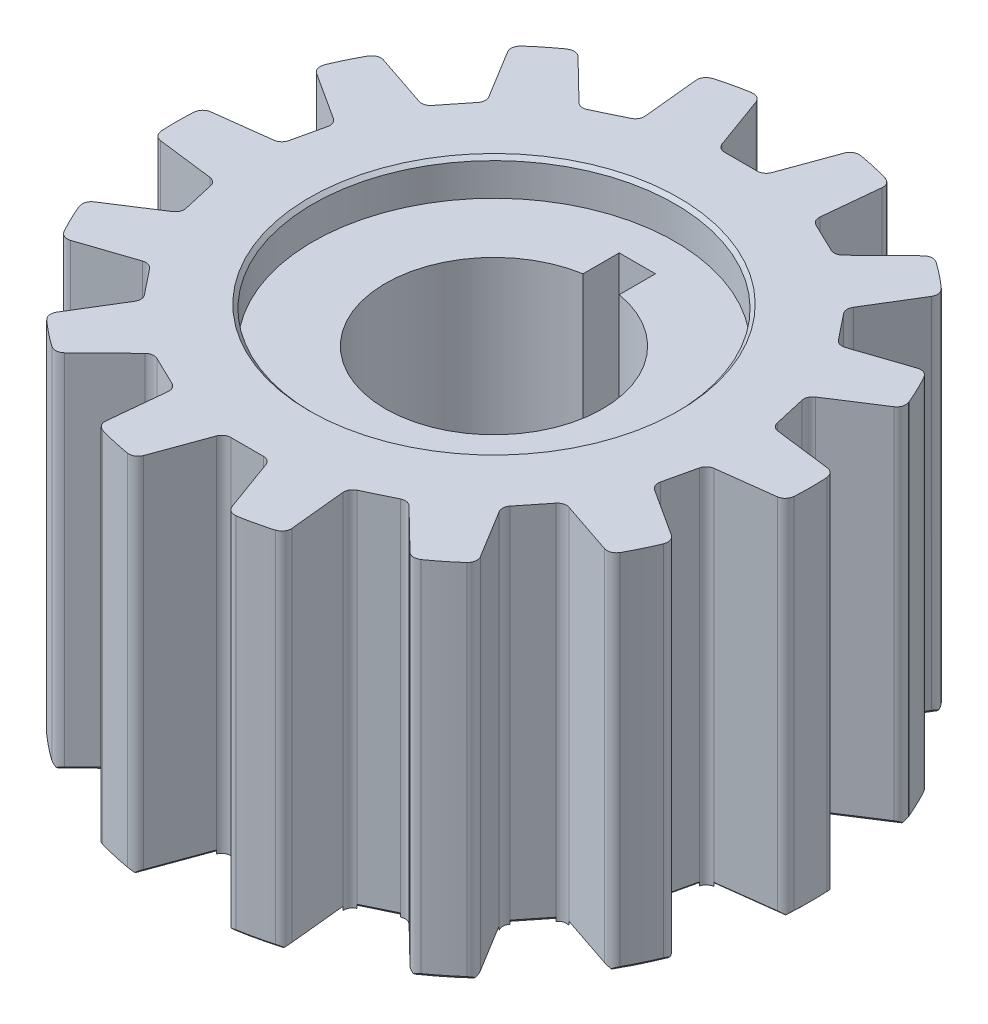
from build123d import *

# Parameters (mm, degrees)
CROQUIS1_R              = 17.5
CROQUIS1_R_2            = 6
SALIENTE_EXTRUIR1_DEPTH = 20
CORTAR_EXTRUIR2_DEPTH   = 20
CORTAR_EXTRUIR3_DEPTH   = 20
CROQUIS4_R              = 10
CORTAR_EXTRUIR4_DEPTH   = 2
CROQUIS5_R              = 10
CORTAR_EXTRUIR5_DEPTH   = 2
CHAFL_N2_SIZE           = 0.2
CHAFL_N3_SIZE           = 0.2
SALIENTE_EXTRUIR3_DEPTH = 20
CORTAR_EXTRUIR9_DEPTH   = 20


with BuildPart() as part:
    # Croquis1 → Saliente-Extruir1 (new body)
    with BuildSketch(Plane(origin=(0, 0, 0), x_dir=(1, 0, 0), z_dir=(0, 1, 0))):
        Circle(CROQUIS1_R)
        Circle(CROQUIS1_R_2, mode=Mode.SUBTRACT)
    extrude(amount=SALIENTE_EXTRUIR1_DEPTH)

    # Croquis2 → Cortar-Extruir2 (cut)
    with BuildSketch(Plane(origin=(0, 20, 0), x_dir=(1, 0, 0), z_dir=(0, 1, 0))):
        with BuildLine():
            Line((5.915999659, 12.284699873), (7.042210744, 11.7423452))
            Line((7.042210744, 11.7423452), (9.84016384, 14.471391626))
            ThreePointArc((9.84016384, 14.471391626), (7.592965435, 15.766955188), (5.178947766, 16.71611498))
            Line((5.178947766, 16.71611498), (4.789788574, 12.827054547))
            Line((4.789788574, 12.827054547), (5.915999659, 12.284699873))
        make_face()
        with BuildLine():
            Line((0, 13.63498819), (-1.25, 13.63498819))
            Line((-1.25, 13.63498819), (-2.586779766, 17.307760411))
            ThreePointArc((-2.586779766, 17.307760411), (0, 17.5), (2.586779766, 17.307760411))
            Line((2.586779766, 17.307760411), (1.25, 13.63498819))
            Line((1.25, 13.63498819), (0, 13.63498819))
        make_face()
        with BuildLine():
            Line((10.66026303, 8.501276085), (11.439625282, 7.523986732))
            Line((11.439625282, 7.523986732), (15.144582784, 8.76878625))
            ThreePointArc((15.144582784, 8.76878625), (13.682050943, 10.911071533), (11.918921177, 12.813637968))
            Line((11.918921177, 12.813637968), (9.880900778, 9.478565438))
            Line((9.880900778, 9.478565438), (10.66026303, 8.501276085))
        make_face()
        with BuildLine():
            Line((13.293130569, 3.034070307), (13.571281736, 1.815410416))
            Line((13.571281736, 1.815410416), (17.449431371, 1.329415215))
            ThreePointArc((17.449431371, 1.329415215), (17.061238463, 3.894116344), (16.298206073, 6.373262808))
            Line((16.298206073, 6.373262808), (13.014979401, 4.252730197))
            Line((13.014979401, 4.252730197), (13.293130569, 3.034070307))
        make_face()
        with BuildLine():
            Line((13.293130569, -3.034070307), (13.014979401, -4.252730197))
            Line((13.014979401, -4.252730197), (16.298206073, -6.373262808))
            ThreePointArc((16.298206073, -6.373262808), (17.061238463, -3.894116344), (17.449431371, -1.329415215))
            Line((17.449431371, -1.329415215), (13.571281736, -1.815410416))
            Line((13.571281736, -1.815410416), (13.293130569, -3.034070307))
        make_face()
        with BuildLine():
            Line((10.66026303, -8.501276085), (9.880900778, -9.478565438))
            Line((9.880900778, -9.478565438), (11.918921177, -12.813637968))
            ThreePointArc((11.918921177, -12.813637968), (13.682050943, -10.911071533), (15.144582784, -8.76878625))
            Line((15.144582784, -8.76878625), (11.439625282, -7.523986732))
            Line((11.439625282, -7.523986732), (10.66026303, -8.501276085))
        make_face()
        with BuildLine():
            Line((5.915999659, -12.284699873), (4.789788574, -12.827054547))
            Line((4.789788574, -12.827054547), (5.178947766, -16.71611498))
            ThreePointArc((5.178947766, -16.71611498), (7.592965435, -15.766955188), (9.84016384, -14.471391626))
            Line((9.84016384, -14.471391626), (7.042210744, -11.7423452))
            Line((7.042210744, -11.7423452), (5.915999659, -12.284699873))
        make_face()
        with BuildLine():
            Line((0, -13.63498819), (-1.25, -13.63498819))
            Line((-1.25, -13.63498819), (-2.586779766, -17.307760411))
            ThreePointArc((-2.586779766, -17.307760411), (0, -17.5), (2.586779766, -17.307760411))
            Line((2.586779766, -17.307760411), (1.25, -13.63498819))
            Line((1.25, -13.63498819), (0, -13.63498819))
        make_face()
        with BuildLine():
            Line((-5.915999659, -12.284699873), (-7.042210744, -11.7423452))
            Line((-7.042210744, -11.7423452), (-9.84016384, -14.471391626))
            ThreePointArc((-9.84016384, -14.471391626), (-7.592965435, -15.766955188), (-5.178947766, -16.71611498))
            Line((-5.178947766, -16.71611498), (-4.789788574, -12.827054547))
            Line((-4.789788574, -12.827054547), (-5.915999659, -12.284699873))
        make_face()
        with BuildLine():
            Line((-10.66026303, -8.501276085), (-11.439625282, -7.523986732))
            Line((-11.439625282, -7.523986732), (-15.144582784, -8.76878625))
            ThreePointArc((-15.144582784, -8.76878625), (-13.682050943, -10.911071533), (-11.918921177, -12.813637968))
            Line((-11.918921177, -12.813637968), (-9.880900778, -9.478565438))
            Line((-9.880900778, -9.478565438), (-10.66026303, -8.501276085))
        make_face()
        with BuildLine():
            Line((-13.293130569, -3.034070307), (-13.571281736, -1.815410416))
            Line((-13.571281736, -1.815410416), (-17.449431371, -1.329415215))
            ThreePointArc((-17.449431371, -1.329415215), (-17.061238463, -3.894116344), (-16.298206073, -6.373262808))
            Line((-16.298206073, -6.373262808), (-13.014979401, -4.252730197))
            Line((-13.014979401, -4.252730197), (-13.293130569, -3.034070307))
        make_face()
        with BuildLine():
            Line((-13.293130569, 3.034070307), (-13.014979401, 4.252730197))
            Line((-13.014979401, 4.252730197), (-16.298206073, 6.373262808))
            ThreePointArc((-16.298206073, 6.373262808), (-17.061238463, 3.894116344), (-17.449431371, 1.329415215))
            Line((-17.449431371, 1.329415215), (-13.571281736, 1.815410416))
            Line((-13.571281736, 1.815410416), (-13.293130569, 3.034070307))
        make_face()
        with BuildLine():
            Line((-10.66026303, 8.501276085), (-9.880900778, 9.478565438))
            Line((-9.880900778, 9.478565438), (-11.918921177, 12.813637968))
            ThreePointArc((-11.918921177, 12.813637968), (-13.682050943, 10.911071533), (-15.144582784, 8.76878625))
            Line((-15.144582784, 8.76878625), (-11.439625282, 7.523986732))
            Line((-11.439625282, 7.523986732), (-10.66026303, 8.501276085))
        make_face()
        with BuildLine():
            Line((-5.915999659, 12.284699873), (-4.789788574, 12.827054547))
            Line((-4.789788574, 12.827054547), (-5.178947766, 16.71611498))
            ThreePointArc((-5.178947766, 16.71611498), (-7.592965435, 15.766955188), (-9.84016384, 14.471391626))
            Line((-9.84016384, 14.471391626), (-7.042210744, 11.7423452))
            Line((-7.042210744, 11.7423452), (-5.915999659, 12.284699873))
        make_face()
    extrude(amount=-CORTAR_EXTRUIR2_DEPTH, mode=Mode.SUBTRACT)

    # Croquis3 → Cortar-Extruir3 (cut)
    with BuildSketch(Plane(origin=(0, 20, 0), x_dir=(1, 0, 0), z_dir=(0, 1, 0))):
        with BuildLine():
            Line((-1, 5.916079783), (-1, 7.916079783))
            Line((-1, 7.916079783), (1, 7.916079783))
            Line((1, 7.916079783), (1, 5.916079783))
            ThreePointArc((1, 5.916079783), (0, 6), (-1, 5.916079783))
        make_face()
    extrude(amount=-CORTAR_EXTRUIR3_DEPTH, mode=Mode.SUBTRACT)

    # Croquis4 → Cortar-Extruir4 (cut)
    with BuildSketch(Plane(origin=(0, 20, 0), x_dir=(1, 0, 0), z_dir=(0, 1, 0))):
        Circle(CROQUIS4_R)
    extrude(amount=-CORTAR_EXTRUIR4_DEPTH, mode=Mode.SUBTRACT)

    # Croquis5 → Cortar-Extruir5 (cut)
    with BuildSketch(Plane.XZ):
        Circle(CROQUIS5_R)
    extrude(amount=-CORTAR_EXTRUIR5_DEPTH, mode=Mode.SUBTRACT)

    # Chaflán2
    chafl_n2_edges = [part.edges().sort_by_distance(p)[0] for p in [
        (10.899910977, 0, 11.146101703),
        (10.66026303, 0, 8.501276085),
        (13.292104033, 0, 8.146386491),
        (4.98436817, 0, 14.771584764),
        (5.915999659, 0, 12.284699873),
        (8.441187292, 0, 13.106868413),
        (-1.918389883, 0, 15.471374301),
        (0, 0, 13.63498819),
        (1.918389883, 0, 15.471374301),
        (-8.441187292, 0, 13.106868413),
        (-5.915999659, 0, 12.284699873),
        (-4.98436817, 0, 14.771584764),
        (-13.292104033, 0, 8.146386491),
        (-10.66026303, 0, 8.501276085),
        (-10.899910977, 0, 11.146101703),
        (-15.510356554, 0, 1.572412816),
        (-13.293130569, 0, 3.034070307),
        (-14.656592737, 0, 5.312996502),
        (-14.656592737, 0, -5.312996502),
        (-13.293130569, 0, -3.034070307),
        (-15.510356554, 0, -1.572412816),
        (-10.899910977, 0, -11.146101703),
        (-10.66026303, 0, -8.501276085),
        (-13.292104033, 0, -8.146386491),
        (-4.98436817, 0, -14.771584764),
        (-5.915999659, 0, -12.284699873),
        (-8.441187292, 0, -13.106868413),
        (1.918389883, 0, -15.471374301),
        (0, 0, -13.63498819),
        (-1.918389883, 0, -15.471374301),
        (10.911071533, 0, 13.682050943),
        (15.766955188, 0, 7.592965435),
        (17.5, 0, 0),
        (3.894116344, 0, 17.061238463),
        (15.766955188, 0, -7.592965435),
        (10.911071533, 0, -13.682050943),
        (3.894116344, 0, -17.061238463),
        (-3.894116344, 0, -17.061238463),
        (-10.911071533, 0, -13.682050943),
        (-15.766955188, 0, -7.592965435),
        (-17.5, 0, 0),
        (-15.766955188, 0, 7.592965435),
        (-10.911071533, 0, 13.682050943),
        (-3.894116344, 0, 17.061238463),
        (-10, 0, 0),
        (8.441187292, 0, -13.106868413),
        (5.915999659, 0, -12.284699873),
        (4.98436817, 0, -14.771584764),
        (13.292104033, 0, -8.146386491),
        (10.66026303, 0, -8.501276085),
        (10.899910977, 0, -11.146101703),
        (15.510356554, 0, -1.572412816),
        (13.293130569, 0, -3.034070307),
        (14.656592737, 0, -5.312996502),
        (14.656592737, 0, 5.312996502),
        (13.293130569, 0, 3.034070307),
        (15.510356554, 0, 1.572412816),
    ]]
    chamfer(chafl_n2_edges, length=CHAFL_N2_SIZE)

    # Chaflán3
    chafl_n3_edges = [part.edges().sort_by_distance(p)[0] for p in [
        (-10, 20, 0),
    ]]
    chamfer(chafl_n3_edges, length=CHAFL_N3_SIZE)

    # Croquis6 → Saliente-Extruir3 (add)
    with BuildSketch(Plane(origin=(0, 20, 0), x_dir=(1, 0, 0), z_dir=(0, 1, 0))):
        with BuildLine():
            Line((-11.771498219, 7.635490109), (-11.439625282, 7.523986732))
            Line((-11.439625282, 7.523986732), (-11.221339153, 7.797708881))
            ThreePointArc((-11.221339153, 7.797708881), (-11.470844995, 7.629867251), (-11.771498219, 7.635490109))
        make_face()
        with BuildLine():
            Line((-4.789788574, 12.827054547), (-4.824647652, 13.175418572))
            ThreePointArc((-4.824647652, 13.175418572), (-4.886067408, 12.881052148), (-5.10522117, 12.675150215))
            Line((-5.10522117, 12.675150215), (-4.789788574, 12.827054547))
        make_face()
        with BuildLine():
            Line((-10.099186907, 9.204843289), (-9.880900778, 9.478565438))
            Line((-9.880900778, 9.478565438), (-10.063457208, 9.777305792))
            ThreePointArc((-10.063457208, 9.777305792), (-9.991073691, 9.485441775), (-10.099186907, 9.204843289))
        make_face()
        with BuildLine():
            Line((-7.042210744, 11.7423452), (-6.726778147, 11.894249532))
            ThreePointArc((-6.726778147, 11.894249532), (-7.024398897, 11.851285977), (-7.292838426, 11.986800541))
            Line((-7.292838426, 11.986800541), (-7.042210744, 11.7423452))
        make_face()
        with BuildLine():
            Line((1.25, 13.63498819), (1.369742541, 13.963978118))
            ThreePointArc((1.369742541, 13.963978118), (1.186684449, 13.725412168), (0.899896231, 13.63498819))
            Line((0.899896231, 13.63498819), (1.25, 13.63498819))
        make_face()
        with BuildLine():
            Line((-1.25, 13.63498819), (-0.899896231, 13.63498819))
            ThreePointArc((-0.899896231, 13.63498819), (-1.186684449, 13.725412168), (-1.369742541, 13.963978118))
            Line((-1.369742541, 13.963978118), (-1.25, 13.63498819))
        make_face()
        with BuildLine():
            Line((7.042210744, 11.7423452), (7.292838426, 11.986800541))
            ThreePointArc((7.292838426, 11.986800541), (7.024398897, 11.851285977), (6.726778147, 11.894249532))
            Line((6.726778147, 11.894249532), (7.042210744, 11.7423452))
        make_face()
        with BuildLine():
            Line((4.789788574, 12.827054547), (5.10522117, 12.675150215))
            ThreePointArc((5.10522117, 12.675150215), (4.886067408, 12.881052148), (4.824647652, 13.175418572))
            Line((4.824647652, 13.175418572), (4.789788574, 12.827054547))
        make_face()
        with BuildLine():
            Line((11.439625282, 7.523986732), (11.771498219, 7.635490109))
            ThreePointArc((11.771498219, 7.635490109), (11.470844995, 7.629867251), (11.221339153, 7.797708881))
            Line((11.221339153, 7.797708881), (11.439625282, 7.523986732))
        make_face()
        with BuildLine():
            Line((9.880900778, 9.478565438), (10.099186907, 9.204843289))
            ThreePointArc((10.099186907, 9.204843289), (9.991073691, 9.485441775), (10.063457208, 9.777305792))
            Line((10.063457208, 9.777305792), (9.880900778, 9.478565438))
        make_face()
        with BuildLine():
            Line((13.571281736, 1.815410416), (13.918668422, 1.771877217))
            ThreePointArc((13.918668422, 1.771877217), (13.645349561, 1.897259742), (13.493376319, 2.156736353))
            Line((13.493376319, 2.156736353), (13.571281736, 1.815410416))
        make_face()
        with BuildLine():
            Line((13.014979401, 4.252730197), (13.092884819, 3.91140426))
            ThreePointArc((13.092884819, 3.91140426), (13.117225297, 4.211123327), (13.309075643, 4.442677689))
            Line((13.309075643, 4.442677689), (13.014979401, 4.252730197))
        make_face()
        with BuildLine():
            Line((13.014979401, -4.252730197), (13.309075643, -4.442677689))
            ThreePointArc((13.309075643, -4.442677689), (13.117225297, -4.211123327), (13.092884819, -3.91140426))
            Line((13.092884819, -3.91140426), (13.014979401, -4.252730197))
        make_face()
        with BuildLine():
            Line((13.571281736, -1.815410416), (13.493376319, -2.156736353))
            ThreePointArc((13.493376319, -2.156736353), (13.645349561, -1.897259742), (13.918668422, -1.771877217))
            Line((13.918668422, -1.771877217), (13.571281736, -1.815410416))
        make_face()
        with BuildLine():
            Line((9.880900778, -9.478565438), (10.063457208, -9.777305792))
            ThreePointArc((10.063457208, -9.777305792), (9.991073691, -9.485441775), (10.099186907, -9.204843289))
            Line((10.099186907, -9.204843289), (9.880900778, -9.478565438))
        make_face()
        with BuildLine():
            Line((11.439625282, -7.523986732), (11.221339153, -7.797708881))
            ThreePointArc((11.221339153, -7.797708881), (11.470844995, -7.629867251), (11.771498219, -7.635490109))
            Line((11.771498219, -7.635490109), (11.439625282, -7.523986732))
        make_face()
        with BuildLine():
            Line((4.789788574, -12.827054547), (4.824647652, -13.175418572))
            ThreePointArc((4.824647652, -13.175418572), (4.886067408, -12.881052148), (5.10522117, -12.675150215))
            Line((5.10522117, -12.675150215), (4.789788574, -12.827054547))
        make_face()
        with BuildLine():
            Line((7.042210744, -11.7423452), (6.726778147, -11.894249532))
            ThreePointArc((6.726778147, -11.894249532), (7.024398897, -11.851285977), (7.292838426, -11.986800541))
            Line((7.292838426, -11.986800541), (7.042210744, -11.7423452))
        make_face()
        with BuildLine():
            Line((-1.25, -13.63498819), (-1.369742541, -13.963978118))
            ThreePointArc((-1.369742541, -13.963978118), (-1.186684449, -13.725412168), (-0.899896231, -13.63498819))
            Line((-0.899896231, -13.63498819), (-1.25, -13.63498819))
        make_face()
        with BuildLine():
            Line((1.25, -13.63498819), (0.899896231, -13.63498819))
            ThreePointArc((0.899896231, -13.63498819), (1.186684449, -13.725412168), (1.369742541, -13.963978118))
            Line((1.369742541, -13.963978118), (1.25, -13.63498819))
        make_face()
        with BuildLine():
            Line((-7.042210744, -11.7423452), (-7.292838426, -11.986800541))
            ThreePointArc((-7.292838426, -11.986800541), (-7.024398897, -11.851285976), (-6.726778147, -11.894249532))
            Line((-6.726778147, -11.894249532), (-7.042210744, -11.7423452))
        make_face()
        with BuildLine():
            Line((-4.789788574, -12.827054547), (-5.10522117, -12.675150215))
            ThreePointArc((-5.10522117, -12.675150215), (-4.886067408, -12.881052148), (-4.824647652, -13.175418572))
            Line((-4.824647652, -13.175418572), (-4.789788574, -12.827054547))
        make_face()
        with BuildLine():
            Line((-11.439625282, -7.523986732), (-11.771498219, -7.635490109))
            ThreePointArc((-11.771498219, -7.635490109), (-11.470844995, -7.629867251), (-11.221339153, -7.797708881))
            Line((-11.221339153, -7.797708881), (-11.439625282, -7.523986732))
        make_face()
        with BuildLine():
            Line((-9.880900778, -9.478565438), (-10.099186907, -9.204843289))
            ThreePointArc((-10.099186907, -9.204843289), (-9.991073691, -9.485441775), (-10.063457208, -9.777305792))
            Line((-10.063457208, -9.777305792), (-9.880900778, -9.478565438))
        make_face()
        with BuildLine():
            Line((-13.571281736, -1.815410416), (-13.918668422, -1.771877217))
            ThreePointArc((-13.918668422, -1.771877217), (-13.645349561, -1.897259742), (-13.493376319, -2.156736353))
            Line((-13.493376319, -2.156736353), (-13.571281736, -1.815410416))
        make_face()
        with BuildLine():
            Line((-13.014979401, -4.252730197), (-13.092884819, -3.91140426))
            ThreePointArc((-13.092884819, -3.91140426), (-13.117225297, -4.211123327), (-13.309075643, -4.442677689))
            Line((-13.309075643, -4.442677689), (-13.014979401, -4.252730197))
        make_face()
        with BuildLine():
            Line((-13.014979401, 4.252730197), (-13.309075643, 4.442677689))
            ThreePointArc((-13.309075643, 4.442677689), (-13.117225297, 4.211123327), (-13.092884819, 3.91140426))
            Line((-13.092884819, 3.91140426), (-13.014979401, 4.252730197))
        make_face()
        with BuildLine():
            Line((-13.571281736, 1.815410416), (-13.493376319, 2.156736353))
            ThreePointArc((-13.493376319, 2.156736353), (-13.645349561, 1.897259742), (-13.918668422, 1.771877217))
            Line((-13.918668422, 1.771877217), (-13.571281736, 1.815410416))
        make_face()
    extrude(amount=-SALIENTE_EXTRUIR3_DEPTH)

    # Croquis8 → Cortar-Extruir9 (cut)
    with BuildSketch(Plane(origin=(0, 20, 0), x_dir=(1, 0, 0), z_dir=(0, 1, 0))):
        with BuildLine():
            Line((-11.697508312, 12.451311879), (-11.918921177, 12.813637968))
            Line((-11.918921177, 12.813637968), (-12.158990551, 13.206494083))
            Line((-12.158990551, 13.206494083), (-11.758081333, 13.451484607))
            Line((-11.758081333, 13.451484607), (-11.597241489, 13.090813057))
            ThreePointArc((-11.597241489, 13.090813057), (-11.764828202, 12.789477867), (-11.697508312, 12.451311879))
        make_face()
        with BuildLine():
            Line((-10.111574554, 14.749550429), (-10.327336878, 14.471391626))
            Line((-10.327336878, 14.471391626), (-10.181970035, 14.219454379))
            ThreePointArc((-10.181970035, 14.219454379), (-9.850898396, 14.315785956), (-9.536191019, 14.174904905))
            Line((-9.536191019, 14.174904905), (-9.84016384, 14.471391626))
            ThreePointArc((-9.84016384, 14.471391626), (-9.966261553, 14.619845591), (-10.111574554, 14.749550429))
        make_face()
        with BuildLine():
            Line((-5.136669067, 16.293603012), (-5.178947766, 16.71611498))
            Line((-5.178947766, 16.71611498), (-5.224788918, 17.174228307))
            Line((-5.224788918, 17.174228307), (-4.757284789, 17.221009151))
            Line((-4.757284789, 17.221009151), (-4.768862617, 16.826269521))
            ThreePointArc((-4.768862617, 16.826269521), (-5.050597468, 16.627489045), (-5.136669067, 16.293603012))
        make_face()
        with BuildLine():
            Line((-2.586779766, 17.307760411), (-2.441550485, 16.908746241))
            ThreePointArc((-2.441550485, 16.908746241), (-2.663966036, 17.172222095), (-3.004047982, 17.229076945))
            Line((-3.004047982, 17.229076945), (-3.025707506, 17.51913687))
            Line((-3.025707506, 17.51913687), (-2.710623788, 17.676133528))
            ThreePointArc((-2.710623788, 17.676133528), (-2.635978118, 17.496224559), (-2.586779766, 17.307760411))
        make_face()
        with BuildLine():
            Line((2.441550485, 16.908746241), (2.586779766, 17.307760411))
            Line((2.586779766, 17.307760411), (2.744246238, 17.740395987))
            Line((2.744246238, 17.740395987), (3.185750351, 17.579701631))
            Line((3.185750351, 17.579701631), (3.004047982, 17.229076945))
            ThreePointArc((3.004047982, 17.229076945), (2.663966036, 17.172222095), (2.441550485, 16.908746241))
        make_face()
        with BuildLine():
            Line((5.178947766, 16.71611498), (5.136669067, 16.293603012))
            ThreePointArc((5.136669067, 16.293603012), (5.050597468, 16.627489045), (4.768862617, 16.826269521))
            Line((4.768862617, 16.826269521), (4.875200345, 17.097002199))
            Line((4.875200345, 17.097002199), (5.227199263, 17.101741598))
            ThreePointArc((5.227199263, 17.101741598), (5.216393111, 16.907261676), (5.178947766, 16.71611498))
        make_face()
        with BuildLine():
            Line((9.536191019, 14.174904905), (9.84016384, 14.471391626))
            Line((9.84016384, 14.471391626), (10.16974977, 14.79286067))
            Line((10.16974977, 14.79286067), (10.497808564, 14.456518603))
            Line((10.497808564, 14.456518603), (10.181970035, 14.219454379))
            ThreePointArc((10.181970035, 14.219454379), (9.850898396, 14.315785956), (9.536191019, 14.174904905))
        make_face()
        with BuildLine():
            Line((11.918921177, 12.813637968), (11.697508312, 12.451311879))
            ThreePointArc((11.697508312, 12.451311879), (11.764828202, 12.789477867), (11.597241489, 13.090813057))
            Line((11.597241489, 13.090813057), (11.810514977, 13.288596561))
            Line((11.810514977, 13.288596561), (12.129711392, 13.140140005))
            ThreePointArc((12.129711392, 13.140140005), (12.03559371, 12.969608263), (11.918921177, 12.813637968))
        make_face()
        with BuildLine():
            Line((14.742071968, 8.633549809), (15.144582784, 8.76878625))
            Line((15.144582784, 8.76878625), (15.581009637, 8.915417875))
            Line((15.581009637, 8.915417875), (15.730647043, 8.470044767))
            Line((15.730647043, 8.470044767), (15.34322805, 8.393494484))
            ThreePointArc((15.34322805, 8.393494484), (15.086739514, 8.623932836), (14.742071968, 8.633549809))
        make_face()
        with BuildLine():
            Line((16.298206073, 6.373262808), (15.941512576, 6.142885722))
            ThreePointArc((15.941512576, 6.142885722), (16.148890424, 6.418353745), (16.128644452, 6.76256052))
            Line((16.128644452, 6.76256052), (16.406612272, 6.848221401))
            Line((16.406612272, 6.848221401), (16.629785419, 6.575972532))
            ThreePointArc((16.629785419, 6.575972532), (16.470997368, 6.463164873), (16.298206073, 6.373262808))
        make_face()
        with BuildLine():
            Line((17.028104765, 1.382214289), (17.449431371, 1.329415215))
            Line((17.449431371, 1.329415215), (17.906259457, 1.272167229))
            Line((17.906259457, 1.272167229), (17.847837952, 0.805974687))
            Line((17.847837952, 0.805974687), (17.465571577, 0.905100066))
            ThreePointArc((17.465571577, 0.905100066), (17.334466845, 1.224004053), (17.028104765, 1.382214289))
        make_face()
        with BuildLine():
            Line((17.449431371, -1.329415215), (17.028104765, -1.382214289))
            ThreePointArc((17.028104765, -1.382214289), (17.334466845, -1.224004053), (17.465571577, -0.905100066))
            Line((17.465571577, -0.905100066), (17.753178792, -0.948527996))
            Line((17.753178792, -0.948527996), (17.836126492, -1.290646951))
            ThreePointArc((17.836126492, -1.290646951), (17.644117993, -1.323387586), (17.449431371, -1.329415215))
        make_face()
        with BuildLine():
            Line((15.941512576, -6.142885722), (16.298206073, -6.373262808))
            Line((16.298206073, -6.373262808), (16.684954985, -6.623051739))
            Line((16.684954985, -6.623051739), (16.430045665, -7.017728564))
            Line((16.430045665, -7.017728564), (16.128644452, -6.76256052))
            ThreePointArc((16.128644452, -6.76256052), (16.148890424, -6.418353745), (15.941512576, -6.142885722))
        make_face()
        with BuildLine():
            Line((15.144582784, -8.76878625), (14.742071968, -8.633549809))
            ThreePointArc((14.742071968, -8.633549809), (15.086739514, -8.623932836), (15.34322805, -8.393494484))
            Line((15.34322805, -8.393494484), (15.583510525, -8.557409791))
            Line((15.583510525, -8.557409791), (15.509803969, -8.901637976))
            ThreePointArc((15.509803969, -8.901637976), (15.322604659, -8.847826904), (15.144582784, -8.76878625))
        make_face()
        with BuildLine():
            Line((11.697508312, -12.451311879), (11.918921177, -12.813637968))
            Line((11.918921177, -12.813637968), (12.158990551, -13.206494083))
            Line((12.158990551, -13.206494083), (11.758081333, -13.451484607))
            Line((11.758081333, -13.451484607), (11.597241489, -13.090813057))
            ThreePointArc((11.597241489, -13.090813057), (11.764828202, -12.789477867), (11.697508312, -12.451311879))
        make_face()
        with BuildLine():
            Line((9.84016384, -14.471391626), (9.536191019, -14.174904905))
            ThreePointArc((9.536191019, -14.174904905), (9.850898396, -14.315785956), (10.181970035, -14.219454379))
            Line((10.181970035, -14.219454379), (10.327336878, -14.471391626))
            Line((10.327336878, -14.471391626), (10.111574554, -14.749550429))
            ThreePointArc((10.111574554, -14.749550429), (9.966261553, -14.619845591), (9.84016384, -14.471391626))
        make_face()
        with BuildLine():
            Line((5.136669067, -16.293603012), (5.178947766, -16.71611498))
            Line((5.178947766, -16.71611498), (5.224788918, -17.174228307))
            Line((5.224788918, -17.174228307), (4.757284789, -17.221009151))
            Line((4.757284789, -17.221009151), (4.768862617, -16.826269521))
            ThreePointArc((4.768862617, -16.826269521), (5.050597468, -16.627489045), (5.136669067, -16.293603012))
        make_face()
        with BuildLine():
            Line((2.586779766, -17.307760411), (2.441550485, -16.908746241))
            ThreePointArc((2.441550485, -16.908746241), (2.663966036, -17.172222095), (3.004047982, -17.229076945))
            Line((3.004047982, -17.229076945), (3.025707506, -17.51913687))
            Line((3.025707506, -17.51913687), (2.710623788, -17.676133528))
            ThreePointArc((2.710623788, -17.676133528), (2.635978118, -17.496224559), (2.586779766, -17.307760411))
        make_face()
        with BuildLine():
            Line((-2.441550485, -16.908746241), (-2.586779766, -17.307760411))
            Line((-2.586779766, -17.307760411), (-2.744246238, -17.740395987))
            Line((-2.744246238, -17.740395987), (-3.185750351, -17.579701631))
            Line((-3.185750351, -17.579701631), (-3.004047982, -17.229076945))
            ThreePointArc((-3.004047982, -17.229076945), (-2.663966036, -17.172222095), (-2.441550485, -16.908746241))
        make_face()
        with BuildLine():
            Line((-5.178947766, -16.71611498), (-5.136669067, -16.293603012))
            ThreePointArc((-5.136669067, -16.293603012), (-5.050597468, -16.627489045), (-4.768862617, -16.826269521))
            Line((-4.768862617, -16.826269521), (-4.875200345, -17.097002199))
            Line((-4.875200345, -17.097002199), (-5.227199263, -17.101741598))
            ThreePointArc((-5.227199263, -17.101741598), (-5.216393111, -16.907261676), (-5.178947766, -16.71611498))
        make_face()
        with BuildLine():
            Line((-9.536191019, -14.174904905), (-9.84016384, -14.471391626))
            Line((-9.84016384, -14.471391626), (-10.16974977, -14.79286067))
            Line((-10.16974977, -14.79286067), (-10.497808564, -14.456518603))
            Line((-10.497808564, -14.456518603), (-10.181970035, -14.219454379))
            ThreePointArc((-10.181970035, -14.219454379), (-9.850898396, -14.315785956), (-9.536191019, -14.174904905))
        make_face()
        with BuildLine():
            Line((-11.918921177, -12.813637968), (-11.697508312, -12.451311879))
            ThreePointArc((-11.697508312, -12.451311879), (-11.764828202, -12.789477867), (-11.597241489, -13.090813057))
            Line((-11.597241489, -13.090813057), (-11.810514977, -13.288596561))
            Line((-11.810514977, -13.288596561), (-12.129711392, -13.140140005))
            ThreePointArc((-12.129711392, -13.140140005), (-12.03559371, -12.969608263), (-11.918921177, -12.813637968))
        make_face()
        with BuildLine():
            Line((-14.742071968, -8.633549809), (-15.144582784, -8.76878625))
            Line((-15.144582784, -8.76878625), (-15.581009637, -8.915417875))
            Line((-15.581009637, -8.915417875), (-15.730647043, -8.470044767))
            Line((-15.730647043, -8.470044767), (-15.34322805, -8.393494484))
            ThreePointArc((-15.34322805, -8.393494484), (-15.086739514, -8.623932836), (-14.742071968, -8.633549809))
        make_face()
        with BuildLine():
            Line((-16.298206073, -6.373262808), (-15.941512576, -6.142885722))
            ThreePointArc((-15.941512576, -6.142885722), (-16.148890424, -6.418353745), (-16.128644452, -6.76256052))
            Line((-16.128644452, -6.76256052), (-16.406612272, -6.848221401))
            Line((-16.406612272, -6.848221401), (-16.629785419, -6.575972532))
            ThreePointArc((-16.629785419, -6.575972532), (-16.470997368, -6.463164873), (-16.298206073, -6.373262808))
        make_face()
        with BuildLine():
            Line((-17.028104765, -1.382214289), (-17.449431371, -1.329415215))
            Line((-17.449431371, -1.329415215), (-17.906259457, -1.272167229))
            Line((-17.906259457, -1.272167229), (-17.847837952, -0.805974687))
            Line((-17.847837952, -0.805974687), (-17.465571577, -0.905100066))
            ThreePointArc((-17.465571577, -0.905100066), (-17.334466845, -1.224004053), (-17.028104765, -1.382214289))
        make_face()
        with BuildLine():
            Line((-17.449431371, 1.329415215), (-17.028104765, 1.382214289))
            ThreePointArc((-17.028104765, 1.382214289), (-17.334466845, 1.224004053), (-17.465571577, 0.905100066))
            Line((-17.465571577, 0.905100066), (-17.753178792, 0.948527996))
            Line((-17.753178792, 0.948527996), (-17.836126492, 1.290646951))
            ThreePointArc((-17.836126492, 1.290646951), (-17.644117993, 1.323387586), (-17.449431371, 1.329415215))
        make_face()
        with BuildLine():
            Line((-15.941512576, 6.142885722), (-16.298206073, 6.373262808))
            Line((-16.298206073, 6.373262808), (-16.684954985, 6.623051739))
            Line((-16.684954985, 6.623051739), (-16.430045665, 7.017728564))
            Line((-16.430045665, 7.017728564), (-16.128644452, 6.76256052))
            ThreePointArc((-16.128644452, 6.76256052), (-16.148890424, 6.418353745), (-15.941512576, 6.142885722))
        make_face()
        with BuildLine():
            Line((-15.144582784, 8.76878625), (-14.742071968, 8.633549809))
            ThreePointArc((-14.742071968, 8.633549809), (-15.086739514, 8.623932836), (-15.34322805, 8.393494484))
            Line((-15.34322805, 8.393494484), (-15.583510525, 8.557409791))
            Line((-15.583510525, 8.557409791), (-15.509803969, 8.901637976))
            ThreePointArc((-15.509803969, 8.901637976), (-15.322604659, 8.847826904), (-15.144582784, 8.76878625))
        make_face()
    extrude(amount=-CORTAR_EXTRUIR9_DEPTH, mode=Mode.SUBTRACT)


solid = part.part
